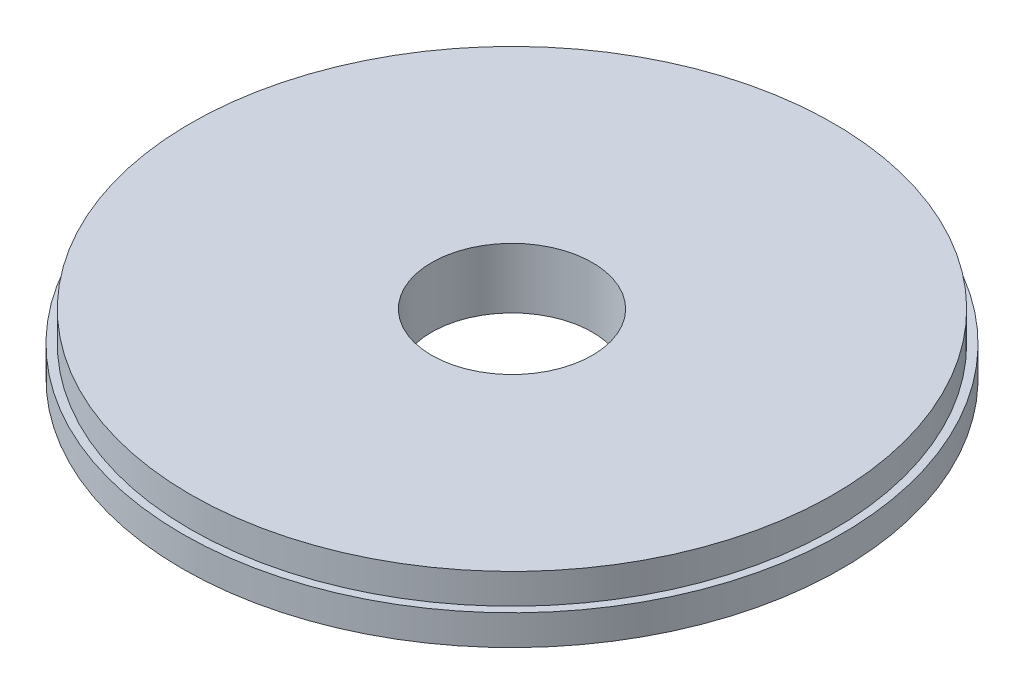
from build123d import *

# Parameters (mm, degrees)
SKETCH1_R           = 101.6
SKETCH1_R_2         = 25.4
BOSS_EXTRUDE1_DEPTH = 9.525
SKETCH2_R           = 104.14
SKETCH2_R_2         = 101.6
BOSS_EXTRUDE2_DEPTH = 9.525


with BuildPart() as part:
    # Sketch1 → Boss-Extrude1 (new body, symmetric)
    with BuildSketch(Plane(origin=(0, 0, 0), x_dir=(1, 0, 0), z_dir=(0, 1, 0))):
        Circle(SKETCH1_R)
        Circle(SKETCH1_R_2, mode=Mode.SUBTRACT)
    extrude(amount=BOSS_EXTRUDE1_DEPTH, both=True)

    # Sketch2 → Boss-Extrude2 (add)
    with BuildSketch(Plane(origin=(0, -9.525, 0), x_dir=(1, 0, 0), z_dir=(0, 1, 0))):
        Circle(SKETCH2_R)
        Circle(SKETCH2_R_2, mode=Mode.SUBTRACT)
    extrude(amount=BOSS_EXTRUDE2_DEPTH)


solid = part.part
